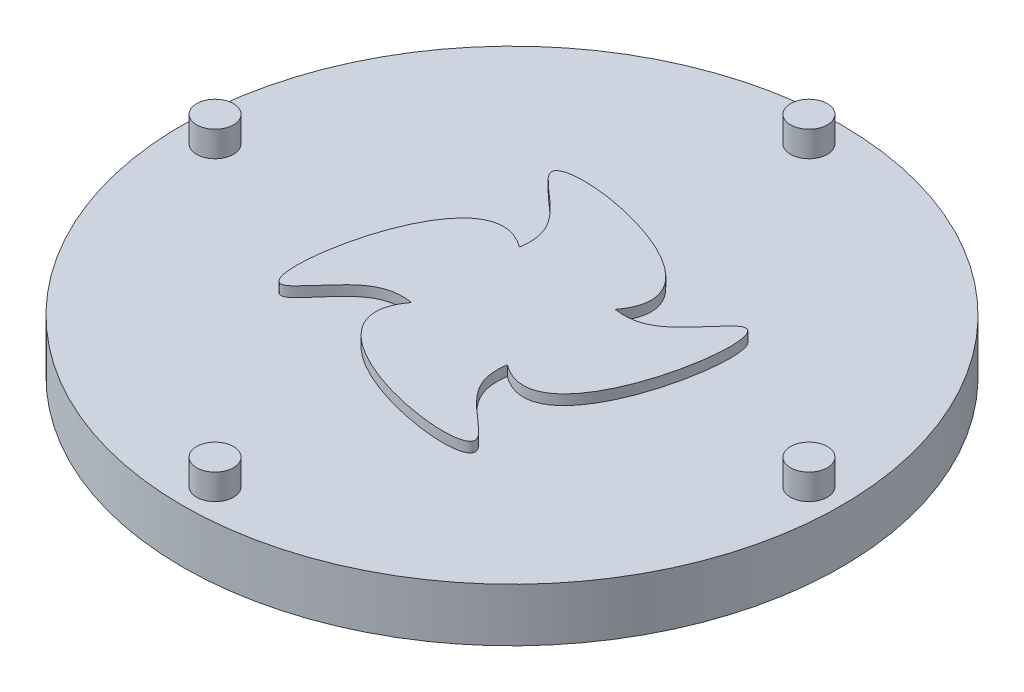
from build123d import *

# Parameters (mm, degrees)
CROQUIS1_R              = 61.815
SALIENTE_EXTRUIR1_DEPTH = 10
CROQUIS2_R              = 3.45
SALIENTE_EXTRUIR2_DEPTH = 4.8
SALIENTE_EXTRUIR5_DEPTH = 11.9
CORTAR_EXTRUIR1_DEPTH   = 3


with BuildPart() as part:
    # Croquis1 → Saliente-Extruir1 (new body)
    with BuildSketch(Plane(origin=(0, 0, 0), x_dir=(1, 0, 0), z_dir=(0, 1, 0))):
        Circle(CROQUIS1_R)
    extrude(amount=SALIENTE_EXTRUIR1_DEPTH)

    # Croquis2 → Saliente-Extruir2 (add)
    with BuildSketch(Plane(origin=(0, 10, 0), x_dir=(1, 0, 0), z_dir=(0, 1, 0))):
        with Locations((0, 55.698306847)):
            Circle(CROQUIS2_R)
        with Locations((55.698306847, 0)):
            Circle(CROQUIS2_R)
        with Locations((0, -55.698306847)):
            Circle(CROQUIS2_R)
        with Locations((-55.698306847, 0)):
            Circle(CROQUIS2_R)
    extrude(amount=SALIENTE_EXTRUIR2_DEPTH)

    # Croquis4 → Saliente-Extruir5 (add)
    with BuildSketch(Plane.XZ):
        with BuildLine():
            add(Edge.make_bspline(
                [(-9.585582496, 9.254104327), (-14.384414082, 15.667728799), (-2.577181856, 26.999350968), (27.202358711, 28.884558567), (9.837232438, 18.603973818), (9.168838491, 12.508556737), (9.516832391, 10.373766238)],
                knots=[0.006190105, 0.006190105, 0.006190105, 0.006190105, 0.153841075, 0.345957591, 0.455748295, 0.513420553, 0.513420553, 0.513420553, 0.513420553], degree=3))
            add(Edge.make_bspline(
                [(9.516832391, 10.373766238), (15.930456761, 15.172597556), (27.262078891, 3.365365311), (29.147286192, -26.414175033), (18.866702111, -9.049049117), (12.771284352, -8.380654758), (10.636493945, -8.728648595)],
                knots=[0.006190107, 0.006190107, 0.006190107, 0.006190107, 0.153841075, 0.345957591, 0.455748295, 0.51342055, 0.51342055, 0.51342055, 0.51342055], degree=3))
            add(Edge.make_bspline(
                [(10.636493945, -8.728648595), (15.435325573, -15.142273032), (3.628093263, -26.473895261), (-26.151447265, -28.359102832), (-8.786320997, -18.078518087), (-8.117927051, -11.983101003), (-8.465920951, -9.848310504)],
                knots=[0.006190105, 0.006190105, 0.006190105, 0.006190105, 0.153841075, 0.345957591, 0.455748295, 0.513420553, 0.513420553, 0.513420553, 0.513420553], degree=3))
            add(Edge.make_bspline(
                [(-8.465920951, -9.848310504), (-14.879545381, -14.64714184), (-26.211167411, -2.839909577), (-28.096374758, 26.939630762), (-17.815790668, 9.574504845), (-11.720372906, 8.906110488), (-9.585582496, 9.254104327)],
                knots=[0.006190107, 0.006190107, 0.006190107, 0.006190107, 0.153841075, 0.345957591, 0.455748295, 0.513420551, 0.513420551, 0.513420551, 0.513420551], degree=3))
        make_face()
    extrude(amount=-SALIENTE_EXTRUIR5_DEPTH)

    # Croquis5 → Cortar-Extruir1 (cut)
    with BuildSketch(Plane.XZ):
        with BuildLine():
            Line((-2.896188532, 35.381663217), (-2.896188532, 36.347846174))
            ThreePointArc((-2.896188532, 36.347846174), (-2.386818184, 41.033378172), (-0.882505152, 45.5))
            Line((-0.882505152, 45.5), (0.882505153, 45.5))
            ThreePointArc((0.882505153, 45.5), (2.386818184, 41.033378172), (2.896188532, 36.347846174))
            Line((2.896188532, 36.347846174), (2.896188532, 35.381663217))
            ThreePointArc((2.896188532, 35.381663217), (4.449329792, 35.220071897), (5.993862389, 34.990336004))
            Line((5.993862389, 34.990336004), (6.23414232, 35.926164547))
            ThreePointArc((6.23414232, 35.926164547), (7.892754286, 40.337816686), (10.460610236, 44.290003938))
            Line((10.460610236, 44.290003938), (12.170169497, 43.851063725))
            ThreePointArc((12.170169497, 43.851063725), (12.51641809, 39.150661596), (11.844541208, 34.485658948))
            Line((11.844541208, 34.485658948), (11.604261277, 33.549830405))
            ThreePointArc((11.604261277, 33.549830405), (13.06842162, 33.007065249), (14.507296893, 32.400437294))
            Line((14.507296893, 32.400437294), (14.972759082, 33.247109874))
            ThreePointArc((14.972759082, 33.247109874), (17.676395976, 37.107681826), (21.146447011, 40.297104042))
            Line((21.146447011, 40.297104042), (22.693137332, 39.446803842))
            ThreePointArc((22.693137332, 39.446803842), (21.859565414, 34.807964967), (20.048657798, 30.456610941))
            Line((20.048657798, 30.456610941), (19.583195608, 29.609938362))
            ThreePointArc((19.583195608, 29.609938362), (20.866376456, 28.7201033), (22.109184579, 27.774699949))
            Line((22.109184579, 27.774699949), (22.770582326, 28.479017013))
            ThreePointArc((22.770582326, 28.479017013), (26.349364698, 31.545934845), (30.50357475, 33.772188896))
            Line((30.50357475, 33.772188896), (31.79021189, 32.563956199))
            ThreePointArc((31.79021189, 32.563956199), (29.82919585, 28.278155884), (26.993043484, 24.513862057))
            Line((26.993043484, 24.513862057), (26.331645737, 23.809544993))
            ThreePointArc((26.331645737, 23.809544993), (27.353220119, 22.628551636), (28.321870886, 21.403776058))
            Line((28.321870886, 21.403776058), (29.137646138, 21.921482775))
            ThreePointArc((29.137646138, 21.921482775), (33.36670593, 24.002040759), (37.944050703, 25.125242916))
            Line((37.944050703, 25.125242916), (38.889790518, 23.634995427))
            ThreePointArc((38.889790518, 23.634995427), (35.924548206, 19.971526267), (32.241356975, 17.030817064))
            Line((32.241356975, 17.030817064), (31.425581724, 16.513110347))
            ThreePointArc((31.425581724, 16.513110347), (32.121360363, 15.115164851), (32.754989884, 13.687974199))
            Line((32.754989884, 13.687974199), (33.673884482, 13.986541153))
            ThreePointArc((33.673884482, 13.986541153), (38.287494314, 14.950010179), (43.000362402, 14.89958552))
            Line((43.000362402, 14.89958552), (43.545780581, 13.220960968))
            ThreePointArc((43.545780581, 13.220960968), (39.762629077, 10.410012204), (35.463827432, 8.477663201))
            Line((35.463827432, 8.477663201), (34.544932835, 8.179096247))
            ThreePointArc((34.544932835, 8.179096247), (34.871197401, 6.652036668), (35.129992404, 5.112106581))
            Line((35.129992404, 5.112106581), (36.09426882, 5.172773711))
            ThreePointArc((36.09426882, 5.172773711), (40.802538619, 4.958615477), (45.354803186, 3.737732369))
            Line((45.354803186, 3.737732369), (45.465629101, 1.976204908))
            ThreePointArc((45.465629101, 1.976204908), (41.102277727, 0.19439879), (36.457975185, -0.608173421))
            Line((36.457975185, -0.608173421), (35.493698769, -0.668840551))
            ThreePointArc((35.493698769, -0.668840551), (35.429948859, -2.229063443), (35.297648302, -3.784973495))
            Line((35.297648302, -3.784973495), (36.246717503, -3.966018127))
            ThreePointArc((36.246717503, -3.966018127), (40.753809361, -5.344347272), (44.859434884, -7.658976254))
            Line((44.859434884, -7.658976254), (44.528704933, -9.392723374))
            ThreePointArc((44.528704933, -9.392723374), (39.859319103, -10.033429416), (35.161334274, -9.65579627))
            Line((35.161334274, -9.65579627), (34.212265073, -9.474751637))
            ThreePointArc((34.212265073, -9.474751637), (33.762506328, -10.9701033), (33.247423141, -12.444229766))
            Line((33.247423141, -12.444229766), (34.121651619, -12.855610461))
            ThreePointArc((34.121651619, -12.855610461), (38.144368379, -15.311505026), (41.545383306, -18.57444323))
            Line((41.545383306, -18.57444323), (40.793878468, -20.171472302))
            ThreePointArc((40.793878468, -20.171472302), (36.111852868, -19.630820351), (31.655377415, -18.096709927))
            Line((31.655377415, -18.096709927), (30.781148938, -17.685329232))
            ThreePointArc((30.781148938, -17.685329232), (29.973641355, -19.021851222), (29.108140109, -20.321569314))
            Line((29.108140109, -20.321569314), (29.852596873, -20.937437509))
            ThreePointArc((29.852596873, -20.937437509), (33.138176447, -24.316584608), (35.620882501, -28.322809627))
            Line((35.620882501, -28.322809627), (34.495822591, -29.682773441))
            ThreePointArc((34.495822591, -29.682773441), (30.095346107, -27.994734646), (26.160396774, -25.400540745))
            Line((26.160396774, -25.400540745), (25.415940011, -24.784672549))
            ThreePointArc((25.415940011, -24.784672549), (24.30142226, -25.878386273), (23.139885582, -26.922029924))
            Line((23.139885582, -26.922029924), (23.707793675, -27.703688356))
            ThreePointArc((23.707793675, -27.703688356), (26.049791015, -31.793763749), (27.458190645, -36.29154973))
            Line((27.458190645, -36.29154973), (26.030267313, -37.328996758))
            ThreePointArc((26.030267313, -37.328996758), (22.187838067, -34.599636806), (19.021662192, -31.108362171))
            Line((19.021662192, -31.108362171), (18.453754099, -30.326703739))
            ThreePointArc((18.453754099, -30.326703739), (17.102255431, -31.108887142), (15.717666941, -31.830880383))
            Line((15.717666941, -31.830880383), (16.07334261, -32.729214577))
            ThreePointArc((16.07334261, -32.729214577), (17.324601408, -37.273223784), (17.570199686, -41.979958293))
            Line((17.570199686, -41.979958293), (15.929134607, -42.629701922))
            ThreePointArc((15.929134607, -42.629701922), (12.886186561, -39.030516537), (10.687726618, -34.861530793))
            Line((10.687726618, -34.861530793), (10.332050949, -33.963196599))
            ThreePointArc((10.332050949, -33.963196599), (8.828490994, -34.38470222), (7.307849481, -34.739679561))
            Line((7.307849481, -34.739679561), (7.428944315, -35.698243876))
            ThreePointArc((7.428944315, -35.698243876), (7.51084338, -40.410670088), (6.578208463, -45.030611685))
            Line((6.578208463, -45.030611685), (4.827115791, -45.251826134))
            ThreePointArc((4.827115791, -45.251826134), (2.77484856, -41.00896537), (1.682241873, -36.424221224))
            Line((1.682241873, -36.424221224), (1.561147039, -35.465656908))
            ThreePointArc((1.561147039, -35.465656908), (0, -35.5), (-1.561147039, -35.465656908))
            Line((-1.561147039, -35.465656908), (-1.682241873, -36.424221224))
            ThreePointArc((-1.682241873, -36.424221224), (-2.77484856, -41.00896537), (-4.827115792, -45.251826134))
            Line((-4.827115792, -45.251826134), (-6.578208463, -45.030611685))
            ThreePointArc((-6.578208463, -45.030611685), (-7.51084338, -40.410670088), (-7.428944315, -35.698243876))
            Line((-7.428944315, -35.698243876), (-7.307849481, -34.739679561))
            ThreePointArc((-7.307849481, -34.739679561), (-8.828490994, -34.38470222), (-10.332050949, -33.963196599))
            Line((-10.332050949, -33.963196599), (-10.687726618, -34.861530793))
            ThreePointArc((-10.687726618, -34.861530793), (-12.886186561, -39.030516537), (-15.929134608, -42.629701922))
            Line((-15.929134608, -42.629701922), (-17.570199687, -41.979958293))
            ThreePointArc((-17.570199687, -41.979958293), (-17.324601409, -37.273223784), (-16.07334261, -32.729214577))
            Line((-16.07334261, -32.729214577), (-15.717666941, -31.830880383))
            ThreePointArc((-15.717666941, -31.830880383), (-17.102255431, -31.108887142), (-18.453754099, -30.326703739))
            Line((-18.453754099, -30.326703739), (-19.021662192, -31.108362171))
            ThreePointArc((-19.021662192, -31.108362171), (-22.187838068, -34.599636806), (-26.030267313, -37.328996758))
            Line((-26.030267313, -37.328996758), (-27.458190645, -36.29154973))
            ThreePointArc((-27.458190645, -36.29154973), (-26.049791015, -31.793763749), (-23.707793675, -27.703688356))
            Line((-23.707793675, -27.703688356), (-23.139885582, -26.922029924))
            ThreePointArc((-23.139885582, -26.922029924), (-24.30142226, -25.878386273), (-25.415940011, -24.784672549))
            Line((-25.415940011, -24.784672549), (-26.160396774, -25.400540745))
            ThreePointArc((-26.160396774, -25.400540745), (-30.095346107, -27.994734646), (-34.495822591, -29.68277344))
            Line((-34.495822591, -29.68277344), (-35.620882502, -28.322809627))
            ThreePointArc((-35.620882502, -28.322809627), (-33.138176447, -24.316584608), (-29.852596873, -20.937437509))
            Line((-29.852596873, -20.937437509), (-29.108140109, -20.321569314))
            ThreePointArc((-29.108140109, -20.321569314), (-29.973641355, -19.021851222), (-30.781148938, -17.685329232))
            Line((-30.781148938, -17.685329232), (-31.655377415, -18.096709927))
            ThreePointArc((-31.655377415, -18.096709927), (-36.111852868, -19.630820351), (-40.793878469, -20.171472302))
            Line((-40.793878469, -20.171472302), (-41.545383306, -18.57444323))
            ThreePointArc((-41.545383306, -18.57444323), (-38.14436838, -15.311505026), (-34.121651619, -12.855610461))
            Line((-34.121651619, -12.855610461), (-33.247423141, -12.444229766))
            ThreePointArc((-33.247423141, -12.444229766), (-33.762506328, -10.9701033), (-34.212265073, -9.474751637))
            Line((-34.212265073, -9.474751637), (-35.161334274, -9.655796269))
            ThreePointArc((-35.161334274, -9.655796269), (-39.859319103, -10.033429416), (-44.528704933, -9.392723373))
            Line((-44.528704933, -9.392723373), (-44.859434884, -7.658976253))
            ThreePointArc((-44.859434884, -7.658976253), (-40.753809361, -5.344347271), (-36.246717503, -3.966018127))
            Line((-36.246717503, -3.966018127), (-35.297648302, -3.784973495))
            ThreePointArc((-35.297648302, -3.784973495), (-35.429948859, -2.229063443), (-35.493698769, -0.668840551))
            Line((-35.493698769, -0.668840551), (-36.457975185, -0.608173421))
            ThreePointArc((-36.457975185, -0.608173421), (-41.102277727, 0.19439879), (-45.4656291, 1.976204909))
            Line((-45.4656291, 1.976204909), (-45.354803186, 3.737732369))
            ThreePointArc((-45.354803186, 3.737732369), (-40.802538619, 4.958615477), (-36.09426882, 5.172773711))
            Line((-36.09426882, 5.172773711), (-35.129992404, 5.112106581))
            ThreePointArc((-35.129992404, 5.112106581), (-34.871197401, 6.652036668), (-34.544932835, 8.179096247))
            Line((-34.544932835, 8.179096247), (-35.463827432, 8.477663201))
            ThreePointArc((-35.463827432, 8.477663201), (-39.762629077, 10.410012204), (-43.545780581, 13.220960968))
            Line((-43.545780581, 13.220960968), (-43.000362402, 14.89958552))
            ThreePointArc((-43.000362402, 14.89958552), (-38.287494314, 14.950010179), (-33.673884482, 13.986541153))
            Line((-33.673884482, 13.986541153), (-32.754989884, 13.687974199))
            ThreePointArc((-32.754989884, 13.687974199), (-32.121360363, 15.115164851), (-31.425581724, 16.513110347))
            Line((-31.425581724, 16.513110347), (-32.241356975, 17.030817064))
            ThreePointArc((-32.241356975, 17.030817064), (-35.924548206, 19.971526267), (-38.889790518, 23.634995427))
            Line((-38.889790518, 23.634995427), (-37.944050703, 25.125242916))
            ThreePointArc((-37.944050703, 25.125242916), (-33.36670593, 24.002040759), (-29.137646138, 21.921482775))
            Line((-29.137646138, 21.921482775), (-28.321870886, 21.403776058))
            ThreePointArc((-28.321870886, 21.403776058), (-27.353220119, 22.628551636), (-26.331645737, 23.809544993))
            Line((-26.331645737, 23.809544993), (-26.993043484, 24.513862057))
            ThreePointArc((-26.993043484, 24.513862057), (-29.82919585, 28.278155884), (-31.790211889, 32.5639562))
            Line((-31.790211889, 32.5639562), (-30.50357475, 33.772188896))
            ThreePointArc((-30.50357475, 33.772188896), (-26.349364698, 31.545934845), (-22.770582326, 28.479017013))
            Line((-22.770582326, 28.479017013), (-22.109184579, 27.774699949))
            ThreePointArc((-22.109184579, 27.774699949), (-20.866376456, 28.7201033), (-19.583195608, 29.609938362))
            Line((-19.583195608, 29.609938362), (-20.048657798, 30.456610941))
            ThreePointArc((-20.048657798, 30.456610941), (-21.859565414, 34.807964967), (-22.693137332, 39.446803842))
            Line((-22.693137332, 39.446803842), (-21.146447011, 40.297104042))
            ThreePointArc((-21.146447011, 40.297104042), (-17.676395976, 37.107681826), (-14.972759082, 33.247109874))
            Line((-14.972759082, 33.247109874), (-14.507296893, 32.400437294))
            ThreePointArc((-14.507296893, 32.400437294), (-13.06842162, 33.007065249), (-11.604261277, 33.549830405))
            Line((-11.604261277, 33.549830405), (-11.844541208, 34.485658948))
            ThreePointArc((-11.844541208, 34.485658948), (-12.516418089, 39.150661596), (-12.170169496, 43.851063725))
            Line((-12.170169496, 43.851063725), (-10.460610235, 44.290003938))
            ThreePointArc((-10.460610235, 44.290003938), (-7.892754285, 40.337816686), (-6.23414232, 35.926164547))
            Line((-6.23414232, 35.926164547), (-5.993862389, 34.990336004))
            ThreePointArc((-5.993862389, 34.990336004), (-4.449329791, 35.220071897), (-2.896188532, 35.381663217))
        make_face()
    extrude(amount=-CORTAR_EXTRUIR1_DEPTH, mode=Mode.SUBTRACT)


solid = part.part
